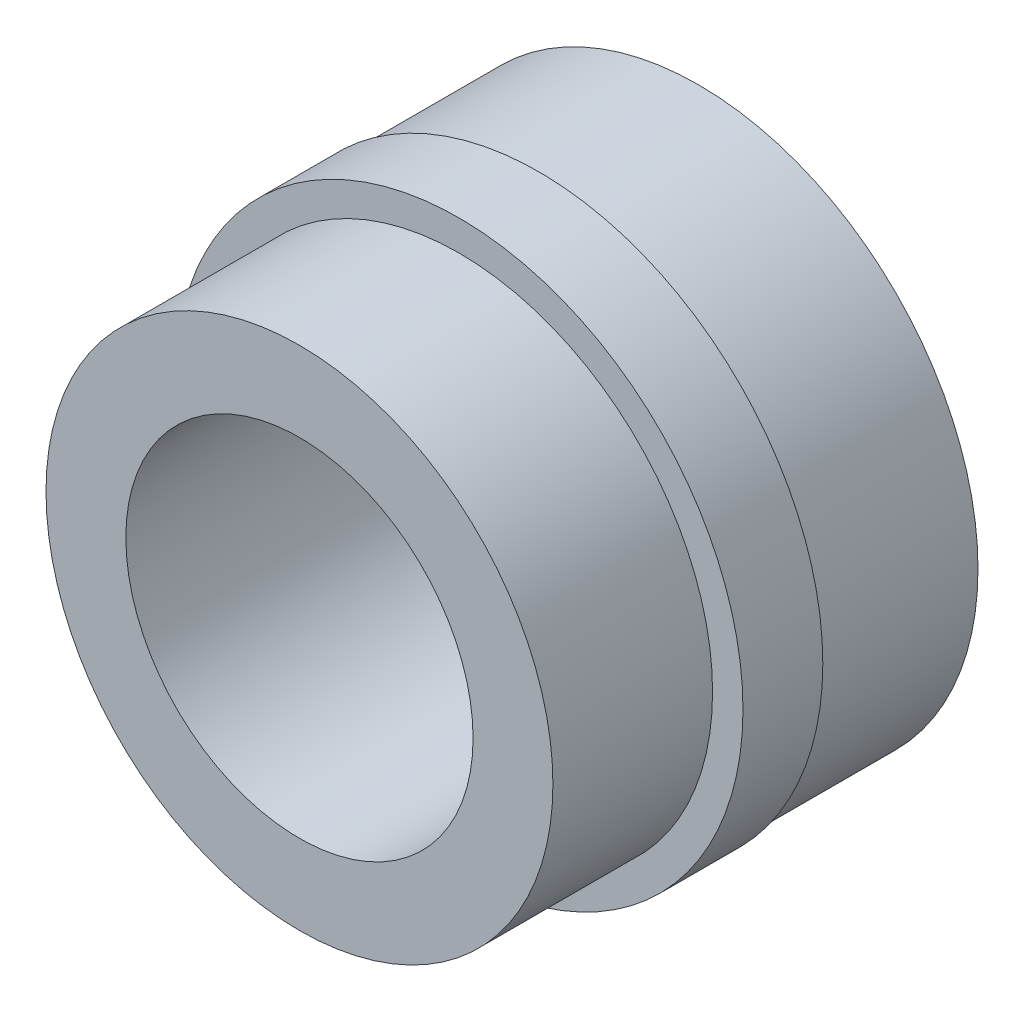
from build123d import *


with BuildPart() as part:
    # Sketch1 → Revolve1 (revolve)
    with BuildSketch(Plane(origin=(0, 0, 0), x_dir=(0, 0, -1), z_dir=(1, 0, 0))):
        Polygon((-6, 6.525), (-6, 9.525), (0, 9.525), (0, 10.668), (3, 10.668), (3, 10.5), (9, 10.5), (9, 6.525), align=None)
    revolve(axis=Axis((0, 0, 52.013823065), (0, 0, -1)))


solid = part.part
